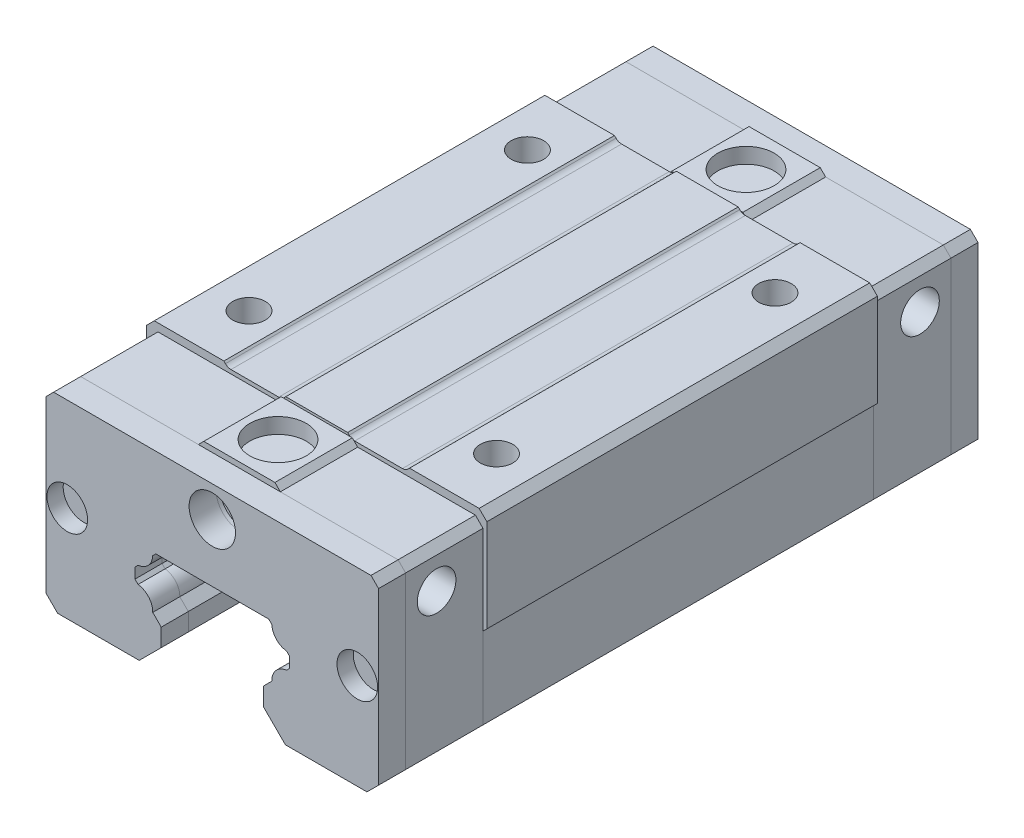
from build123d import *

# Parameters (mm, degrees)
BASE_DEPTH                     = 25.25
GREEN_BODY_DEPTH               = 10
SKETCH5_R                      = 3.65
TOP_HOLE_GB_DEPTH              = 2
SKETCH6_R                      = 2.5
SIDE_HOLE_GB_DEPTH             = 6.7
GREEN_BODY_VM_DEPTH            = 10
GB_FEATURES_VM_COPY_1_SKETCH_R = 2.5
GB_FEATURES_VM_COPY_1_DEPTH    = 6.7
RED_BODY_DEPTH                 = 3.5
SKETCH9_R                      = 2.625
RB_HOLE_DEPTH                  = 2.1
SKETCH10_R                     = 3
CUT_EXTRUDE1_DEPTH             = 4


with BuildPart() as part:
    # Sketch1 → BASE (new body, symmetric)
    with BuildSketch(Plane.XY):
        with BuildLine():
            Line((-7.3, 3.5), (7.3, 3.5))
            Line((7.3, 3.5), (7.7, 3.1))
            ThreePointArc((7.7, 3.1), (8.274662952, 1.735331905), (9.6, 1.075))
            Line((9.6, 1.075), (10, 0.675))
            Line((10, 0.675), (10, -0.675))
            Line((10, -0.675), (9.6, -1.075))
            ThreePointArc((9.6, -1.075), (8.225097216, -1.791320556), (7.7, -3.25))
            Line((7.7, -3.25), (6.6, -4.35))
            Line((6.6, -4.35), (6.6, -6.65))
            Line((6.6, -6.65), (9.45, -9.5))
            Line((9.45, -9.5), (20, -9.5))
            Line((20, -9.5), (21.5, -8))
            Line((21.5, -8), (21.5, 2.5))
            Line((21.5, 2.5), (22, 3))
            Line((22, 3), (22, 15))
            Line((22, 15), (21, 16))
            Line((21, 16), (12, 16))
            Line((12, 16), (11.8, 15.8))
            ThreePointArc((11.8, 15.8), (11.473155492, 15.578045554), (11.085857157, 15.5))
            Line((11.085857157, 15.5), (4.914142843, 15.5))
            ThreePointArc((4.914142843, 15.5), (4.526844508, 15.578045554), (4.2, 15.8))
            Line((4.2, 15.8), (4, 16))
            Line((4, 16), (-4, 16))
            Line((-4, 16), (-4.2, 15.8))
            ThreePointArc((-4.2, 15.8), (-4.526844508, 15.578045554), (-4.914142843, 15.5))
            Line((-4.914142843, 15.5), (-11.085857157, 15.5))
            ThreePointArc((-11.085857157, 15.5), (-11.473155492, 15.578045554), (-11.8, 15.8))
            Line((-11.8, 15.8), (-12, 16))
            Line((-12, 16), (-21, 16))
            Line((-21, 16), (-22, 15))
            Line((-22, 15), (-22, 8))
            Line((-22, 8), (-21.5, 7.5))
            Line((-21.5, 7.5), (-21.5, -8))
            Line((-21.5, -8), (-20, -9.5))
            Line((-20, -9.5), (-9.45, -9.5))
            Line((-9.45, -9.5), (-6.6, -6.65))
            Line((-6.6, -6.65), (-6.6, -4.35))
            Line((-6.6, -4.35), (-7.7, -3.25))
            ThreePointArc((-7.7, -3.25), (-8.225097216, -1.791320556), (-9.6, -1.075))
            Line((-9.6, -1.075), (-10, -0.675))
            Line((-10, -0.675), (-10, 0.675))
            Line((-10, 0.675), (-9.6, 1.075))
            ThreePointArc((-9.6, 1.075), (-8.274662952, 1.735331905), (-7.7, 3.1))
            Line((-7.7, 3.1), (-7.3, 3.5))
        make_face()
    extrude(amount=BASE_DEPTH, both=True)

    # Sketch3 → M5x0.8 Tapped Hole1 (revolve, cut)
    with BuildSketch(Plane(origin=(-16, 16, -18), x_dir=(0, 0, 1), z_dir=(1, 0, 0))):
        Polygon((0, 0), (0, 7.2618073), (2.1, 6), (2.1, 0), align=None)
    m5x0_8_tapped_hole1 = revolve(axis=Axis((-16, 22.35, -18), (0, -1, 0)), mode=Mode.SUBTRACT)

    # HM: M5x0.8 Tapped Hole1 across plane
    add(m5x0_8_tapped_hole1.mirror(Plane(origin=(0, 0, 0), x_dir=(0, 0, 1), z_dir=(1, 0, 0))), mode=Mode.SUBTRACT)

    # VM: M5x0.8 Tapped Hole1 across plane
    add(m5x0_8_tapped_hole1.mirror(Plane.XY), mode=Mode.SUBTRACT)

    # VM copy 1 sketch → VM copy 1 (revolve, cut)
    with BuildSketch(Plane(origin=(16, 16, 18), x_dir=(0, 0, -1), z_dir=(-1, 0, 0))):
        Polygon((0, 0), (0, 7.2618073), (2.1, 6), (2.1, 0), align=None)
    revolve(axis=Axis((16, 22.35, 18), (0, -1, 0)), mode=Mode.SUBTRACT)


with BuildPart() as body_2:
    # Sketch4 → GREEN BODY (new body)
    with BuildSketch(Plane.XY.offset(25.25)):
        with BuildLine():
            Line((-21.5, 14.016514164), (-20.516514164, 15))
            Line((-20.516514164, 15), (-5.3, 15))
            Line((-5.3, 15), (-4.6, 15.7))
            Line((-4.6, 15.7), (4.6, 15.7))
            Line((4.6, 15.7), (5.3, 15))
            Line((5.3, 15), (20.516514164, 15))
            Line((20.516514164, 15), (21.5, 14.016514164))
            Line((21.5, 14.016514164), (21.5, -8))
            Line((21.5, -8), (20, -9.5))
            Line((20, -9.5), (9.45, -9.5))
            Line((9.45, -9.5), (6.6, -6.65))
            Line((6.6, -6.65), (6.6, -4.35))
            Line((6.6, -4.35), (7.7, -3.25))
            ThreePointArc((7.7, -3.25), (8.225097216, -1.791320556), (9.6, -1.075))
            Line((9.6, -1.075), (10, -0.675))
            Line((10, -0.675), (10, 0.675))
            Line((10, 0.675), (9.6, 1.075))
            ThreePointArc((9.6, 1.075), (8.274662952, 1.735331905), (7.7, 3.1))
            Line((7.7, 3.1), (7.3, 3.5))
            Line((7.3, 3.5), (-7.3, 3.5))
            Line((-7.3, 3.5), (-7.7, 3.1))
            ThreePointArc((-7.7, 3.1), (-8.274662952, 1.735331905), (-9.6, 1.075))
            Line((-9.6, 1.075), (-10, 0.675))
            Line((-10, 0.675), (-10, -0.675))
            Line((-10, -0.675), (-9.6, -1.075))
            ThreePointArc((-9.6, -1.075), (-8.225097216, -1.791320556), (-7.7, -3.25))
            Line((-7.7, -3.25), (-6.6, -4.35))
            Line((-6.6, -4.35), (-6.6, -6.65))
            Line((-6.6, -6.65), (-9.45, -9.5))
            Line((-9.45, -9.5), (-20, -9.5))
            Line((-20, -9.5), (-21.5, -8))
            Line((-21.5, -8), (-21.5, 14.016514164))
        make_face()
    extrude(amount=GREEN_BODY_DEPTH)

    # Sketch5 → TOP HOLE GB (cut)
    with BuildSketch(Plane(origin=(0, 15.7, 0), x_dir=(1, 0, 0), z_dir=(0, 1, 0))):
        with Locations((0, -30.25)):
            Circle(SKETCH5_R)
    top_hole_gb = extrude(amount=-TOP_HOLE_GB_DEPTH, mode=Mode.SUBTRACT)

    # Sketch6 → SIDE HOLE GB (cut)
    with BuildSketch(Plane.ZY.offset(21.5)):
        with Locations((31.25, 10)):
            Circle(SKETCH6_R)
    side_hole_gb = extrude(amount=-SIDE_HOLE_GB_DEPTH, mode=Mode.SUBTRACT)

    # SHGB HM: SIDE HOLE GB across plane
    add(side_hole_gb.mirror(Plane(origin=(0, 0, 0), x_dir=(0, 0, 1), z_dir=(1, 0, 0))), mode=Mode.SUBTRACT)


with BuildPart() as body_3:
    # Sketch7 → GREEN BODY VM (new body)
    with BuildSketch(Plane(origin=(0, 0, -25.25), x_dir=(-1, 0, 0), z_dir=(0, 0, -1))):
        with BuildLine():
            Line((-20.516514164, 15), (-21.5, 14.016514164))
            Line((-21.5, 14.016514164), (-21.5, -8))
            Line((-21.5, -8), (-20, -9.5))
            Line((-20, -9.5), (-9.45, -9.5))
            Line((-9.45, -9.5), (-6.6, -6.65))
            Line((-6.6, -6.65), (-6.6, -4.35))
            Line((-6.6, -4.35), (-7.7, -3.25))
            ThreePointArc((-7.7, -3.25), (-8.225097216, -1.791320556), (-9.6, -1.075))
            Line((-9.6, -1.075), (-10, -0.675))
            Line((-10, -0.675), (-10, 0.675))
            Line((-10, 0.675), (-9.6, 1.075))
            ThreePointArc((-9.6, 1.075), (-8.274662952, 1.735331905), (-7.7, 3.1))
            Line((-7.7, 3.1), (-7.3, 3.5))
            Line((-7.3, 3.5), (7.3, 3.5))
            Line((7.3, 3.5), (7.7, 3.1))
            ThreePointArc((7.7, 3.1), (8.274662952, 1.735331905), (9.6, 1.075))
            Line((9.6, 1.075), (10, 0.675))
            Line((10, 0.675), (10, -0.675))
            Line((10, -0.675), (9.6, -1.075))
            ThreePointArc((9.6, -1.075), (8.225097216, -1.791320556), (7.7, -3.25))
            Line((7.7, -3.25), (6.6, -4.35))
            Line((6.6, -4.35), (6.6, -6.65))
            Line((6.6, -6.65), (9.45, -9.5))
            Line((9.45, -9.5), (20, -9.5))
            Line((20, -9.5), (21.5, -8))
            Line((21.5, -8), (21.5, 14.016514164))
            Line((21.5, 14.016514164), (20.516514164, 15))
            Line((20.516514164, 15), (5.3, 15))
            Line((5.3, 15), (4.6, 15.7))
            Line((4.6, 15.7), (-4.6, 15.7))
            Line((-4.6, 15.7), (-5.3, 15))
            Line((-5.3, 15), (-20.516514164, 15))
        make_face()
    extrude(amount=GREEN_BODY_VM_DEPTH)

    # GB FEATURES VM: SIDE HOLE GB, TOP HOLE GB across plane
    add(side_hole_gb.mirror(Plane.XY), mode=Mode.SUBTRACT)
    add(top_hole_gb.mirror(Plane.XY), mode=Mode.SUBTRACT)

    # GB FEATURES VM copy 1 sketch → GB FEATURES VM copy 1 (cut)
    with BuildSketch(Plane(origin=(21.5, 0, 0), x_dir=(0, 0, -1), z_dir=(1, 0, 0))):
        with Locations((31.25, 10)):
            Circle(GB_FEATURES_VM_COPY_1_SKETCH_R)
    extrude(amount=-GB_FEATURES_VM_COPY_1_DEPTH, mode=Mode.SUBTRACT)


with BuildPart() as body_4:
    # Sketch8 → RED BODY (new body)
    with BuildSketch(Plane.XY.offset(35.25)):
        with BuildLine():
            Line((-20.516514164, 15), (20.516514164, 15))
            Line((20.516514164, 15), (21.5, 14.016514164))
            Line((21.5, 14.016514164), (21.5, -8))
            Line((21.5, -8), (20, -9.5))
            Line((20, -9.5), (9.45, -9.5))
            Line((9.45, -9.5), (6.6, -6.65))
            Line((6.6, -6.65), (6.6, -4.35))
            Line((6.6, -4.35), (7.7, -3.25))
            ThreePointArc((7.7, -3.25), (8.225097216, -1.791320556), (9.6, -1.075))
            Line((9.6, -1.075), (10, -0.675))
            Line((10, -0.675), (10, 0.675))
            Line((10, 0.675), (9.6, 1.075))
            ThreePointArc((9.6, 1.075), (8.274662952, 1.735331905), (7.7, 3.1))
            Line((7.7, 3.1), (7.3, 3.5))
            Line((7.3, 3.5), (-7.3, 3.5))
            Line((-7.3, 3.5), (-7.7, 3.1))
            ThreePointArc((-7.7, 3.1), (-8.274662952, 1.735331905), (-9.6, 1.075))
            Line((-9.6, 1.075), (-10, 0.675))
            Line((-10, 0.675), (-10, -0.675))
            Line((-10, -0.675), (-9.6, -1.075))
            ThreePointArc((-9.6, -1.075), (-8.225097216, -1.791320556), (-7.7, -3.25))
            Line((-7.7, -3.25), (-6.6, -4.35))
            Line((-6.6, -4.35), (-6.6, -6.65))
            Line((-6.6, -6.65), (-9.45, -9.5))
            Line((-9.45, -9.5), (-20, -9.5))
            Line((-20, -9.5), (-21.5, -8))
            Line((-21.5, -8), (-21.5, 14.016514164))
            Line((-21.5, 14.016514164), (-20.516514164, 15))
        make_face()
    extrude(amount=RED_BODY_DEPTH)

    # Sketch9 → RB HOLE (cut)
    with BuildSketch(Plane.XY.offset(38.75)):
        with Locations((-18.75, 2.9)):
            Circle(SKETCH9_R)
    rb_hole = extrude(amount=-RB_HOLE_DEPTH, mode=Mode.SUBTRACT)

    # RBH HM: RB HOLE across plane
    add(rb_hole.mirror(Plane(origin=(0, 0, 0), x_dir=(0, 0, 1), z_dir=(1, 0, 0))), mode=Mode.SUBTRACT)


with BuildPart() as body_5:
    # RB AND HOLES VM: mirrored copy
    add(body_4.part.mirror(Plane.XY))


with BuildPart() as cut_extrude1_tool:
    # Sketch10 → Cut-Extrude1 (new body)
    with BuildSketch(Plane.XY.offset(38.75)):
        with Locations((0, 11)):
            Circle(SKETCH10_R)
    extrude(amount=-CUT_EXTRUDE1_DEPTH)


with BuildPart() as body_2_1:
    add(body_2.part)

    # Cut-Extrude1: cut by cut_extrude1_tool
    add(cut_extrude1_tool.part, mode=Mode.SUBTRACT)


with BuildPart() as body_4_1:
    add(body_4.part)

    # Cut-Extrude1: cut by cut_extrude1_tool
    add(cut_extrude1_tool.part, mode=Mode.SUBTRACT)


solid = Compound([part.part, body_3.part, body_5.part, body_2_1.part, body_4_1.part])
